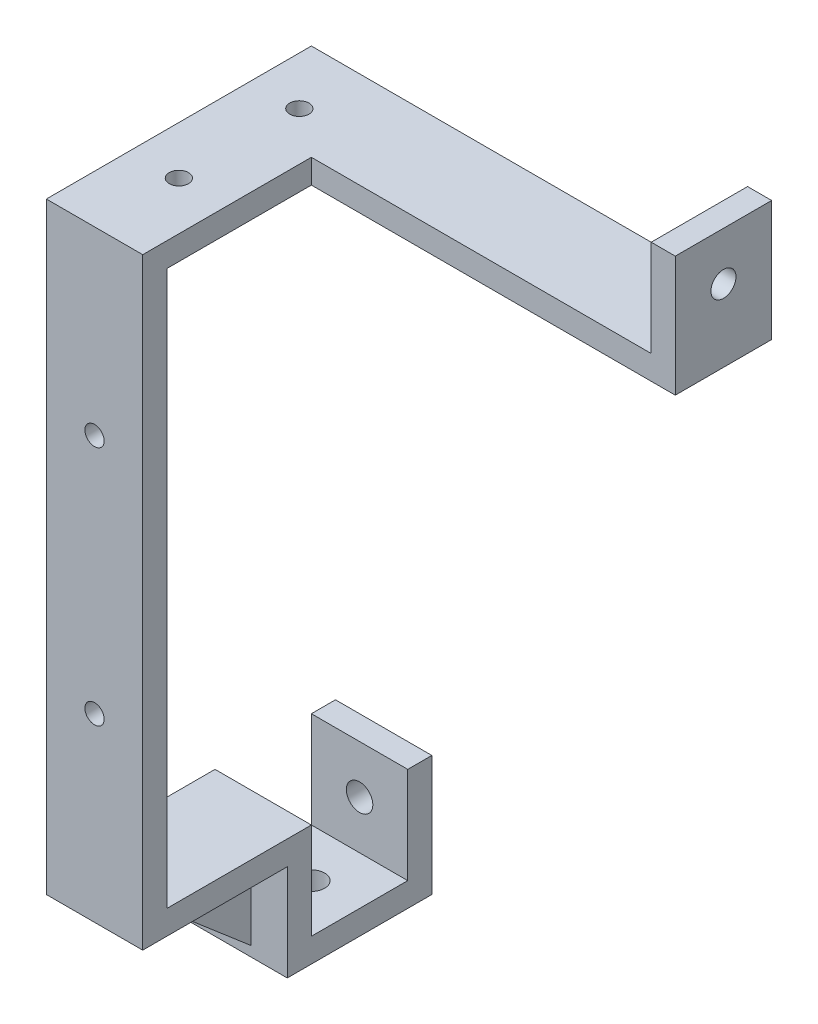
from build123d import *

# Parameters (mm, degrees)
SKETCH_1_W          = 20
SKETCH_1_H          = 145
EXTRUDE_1_DEPTH     = 5
SKETCH_3_W          = 20
SKETCH_3_H          = 5
EXTRUDE_2_DEPTH     = 50
SKETCH_4_W          = 20
SKETCH_4_H          = 5
EXTRUDE_3_DEPTH     = 30
SKETCH_5_W          = 20
SKETCH_5_H          = 20
CUT_EXTRUDE_1_DEPTH = 30
SKETCH_6_W          = 20
SKETCH_6_H          = 5
EXTRUDE_4_DEPTH     = 20
SKETCH_7_W          = 20
SKETCH_7_H          = 5
EXTRUDE_5_DEPTH     = 20
EXTRUDE_6_DEPTH     = 2.5
SKETCH_10_R         = 2
CUT_EXTRUDE_2_DEPTH = 5
SKETCH_11_R         = 2
CUT_EXTRUDE_3_DEPTH = 5
SKETCH_12_R         = 2.75
CUT_EXTRUDE_4_DEPTH = 5
SKETCH_13_W         = 20
SKETCH_13_H         = 5
EXTRUDE_7_DEPTH     = 5
SKETCH_14_W         = 20
SKETCH_14_H         = 5
EXTRUDE_8_DEPTH     = 20
SKETCH_15_R         = 2.75
CUT_EXTRUDE_5_DEPTH = 20
SKETCH_16_W         = 20
SKETCH_16_H         = 5
EXTRUDE_9_DEPTH     = 75.52
SKETCH_17_W         = 5
SKETCH_17_H         = 20
EXTRUDE_10_DEPTH    = 20
SKETCH_18_R         = 2.6
CUT_EXTRUDE_6_DEPTH = 20


with BuildPart() as part:
    # 草图1 → 凸台-拉伸1 (new body)
    with BuildSketch(Plane.XY):
        with Locations((0.170940171, -57.628205128)):
            Rectangle(SKETCH_1_W, SKETCH_1_H)
    extrude(amount=-EXTRUDE_1_DEPTH)

    # 草图3 → 凸台-拉伸2 (add)
    with BuildSketch(Plane(origin=(0, 0, -5), x_dir=(-1, 0, 0), z_dir=(0, 0, -1))):
        with Locations((-0.170940171, 12.371794872)):
            Rectangle(SKETCH_3_W, SKETCH_3_H)
    extrude(amount=EXTRUDE_2_DEPTH)

    # 草图4 → 凸台-拉伸3 (add)
    with BuildSketch(Plane(origin=(0, 0, -5), x_dir=(-1, 0, 0), z_dir=(0, 0, -1))):
        with Locations((-0.170940171, -107.628205128)):
            Rectangle(SKETCH_4_W, SKETCH_4_H)
    extrude(amount=EXTRUDE_3_DEPTH)

    # 草图5 → 切除-拉伸1 (cut)
    with BuildSketch(Plane(origin=(0, 0, -5), x_dir=(-1, 0, 0), z_dir=(0, 0, -1))):
        with Locations((-0.170940171, -120.128205128)):
            Rectangle(SKETCH_5_W, SKETCH_5_H)
    extrude(amount=-CUT_EXTRUDE_1_DEPTH, mode=Mode.SUBTRACT)

    # 草图6 → 凸台-拉伸4 (add)
    with BuildSketch(Plane(origin=(0, -110.128205128, 0), x_dir=(-1, 0, 0), z_dir=(0, -1, 0))):
        with Locations((-0.170940171, 32.5)):
            Rectangle(SKETCH_6_W, SKETCH_6_H)
    extrude(amount=EXTRUDE_4_DEPTH)

    # 草图7 → 凸台-拉伸5 (add)
    with BuildSketch(Plane(origin=(0, 0, -35), x_dir=(-1, 0, 0), z_dir=(0, 0, -1))):
        with Locations((-0.170940171, -127.628205128)):
            Rectangle(SKETCH_7_W, SKETCH_7_H)
    extrude(amount=EXTRUDE_5_DEPTH)

    # 草图9 → 凸台-拉伸6 (add, symmetric)
    with BuildSketch(Plane(origin=(0.170940171, 0, 0), x_dir=(0, 0, -1), z_dir=(1, 0, 0))):
        Polygon((8.965273833, -110.036991646), (29.929169638, -127.991202337), (29.929169638, -110.036991646), align=None)
    extrude(amount=EXTRUDE_6_DEPTH, both=True)

    # 草图10 → 切除-拉伸2 (cut)
    with BuildSketch(Plane.XZ.offset(-9.871794872)):
        with Locations((0.170940171, -17.5)):
            Circle(SKETCH_10_R)
        with Locations((0.170940171, -42.5)):
            Circle(SKETCH_10_R)
    extrude(amount=-CUT_EXTRUDE_2_DEPTH, mode=Mode.SUBTRACT)

    # 草图11 → 切除-拉伸3 (cut)
    with BuildSketch(Plane(origin=(0, 0, -5), x_dir=(-1, 0, 0), z_dir=(0, 0, -1))):
        with Locations((-0.170940171, -22.628205128)):
            Circle(SKETCH_11_R)
        with Locations((-0.170940171, -72.628205128)):
            Circle(SKETCH_11_R)
    extrude(amount=-CUT_EXTRUDE_3_DEPTH, mode=Mode.SUBTRACT)

    # 草图12 → 切除-拉伸4 (cut)
    with BuildSketch(Plane(origin=(0, -125.128205128, 0), x_dir=(1, 0, 0), z_dir=(0, 1, 0))):
        with Locations((0.170940171, 45)):
            Circle(SKETCH_12_R)
    extrude(amount=-CUT_EXTRUDE_4_DEPTH, mode=Mode.SUBTRACT)

    # 草图13 → 凸台-拉伸7 (add)
    with BuildSketch(Plane(origin=(0, 0, -55), x_dir=(-1, 0, 0), z_dir=(0, 0, -1))):
        with Locations((-0.170940171, -127.628205128)):
            Rectangle(SKETCH_13_W, SKETCH_13_H)
    extrude(amount=EXTRUDE_7_DEPTH)

    # 草图14 → 凸台-拉伸8 (add)
    with BuildSketch(Plane(origin=(0, -125.128205128, 0), x_dir=(1, 0, 0), z_dir=(0, 1, 0))):
        with Locations((0.170940171, 57.5)):
            Rectangle(SKETCH_14_W, SKETCH_14_H)
    extrude(amount=EXTRUDE_8_DEPTH)

    # 草图15 → 切除-拉伸5 (cut)
    with BuildSketch(Plane.XY.offset(-55)):
        with Locations((0.170940171, -115.12820513)):
            Circle(SKETCH_15_R)
    extrude(amount=-CUT_EXTRUDE_5_DEPTH, mode=Mode.SUBTRACT)

    # 草图16 → 凸台-拉伸9 (add)
    with BuildSketch(Plane(origin=(10.170940171, 0, 0), x_dir=(0, 0, -1), z_dir=(1, 0, 0))):
        with Locations((45, 12.371794872)):
            Rectangle(SKETCH_16_W, SKETCH_16_H)
    extrude(amount=EXTRUDE_9_DEPTH)

    # 草图17 → 凸台-拉伸10 (add)
    with BuildSketch(Plane(origin=(0, 14.871794872, 0), x_dir=(1, 0, 0), z_dir=(0, 1, 0))):
        with Locations((83.190940171, 45)):
            Rectangle(SKETCH_17_W, SKETCH_17_H)
    extrude(amount=EXTRUDE_10_DEPTH)

    # 草图18 → 切除-拉伸6 (cut)
    with BuildSketch(Plane.ZY.offset(-80.690940171)):
        with Locations((-45, 24.871794872)):
            Circle(SKETCH_18_R)
    extrude(amount=-CUT_EXTRUDE_6_DEPTH, mode=Mode.SUBTRACT)


solid = part.part
